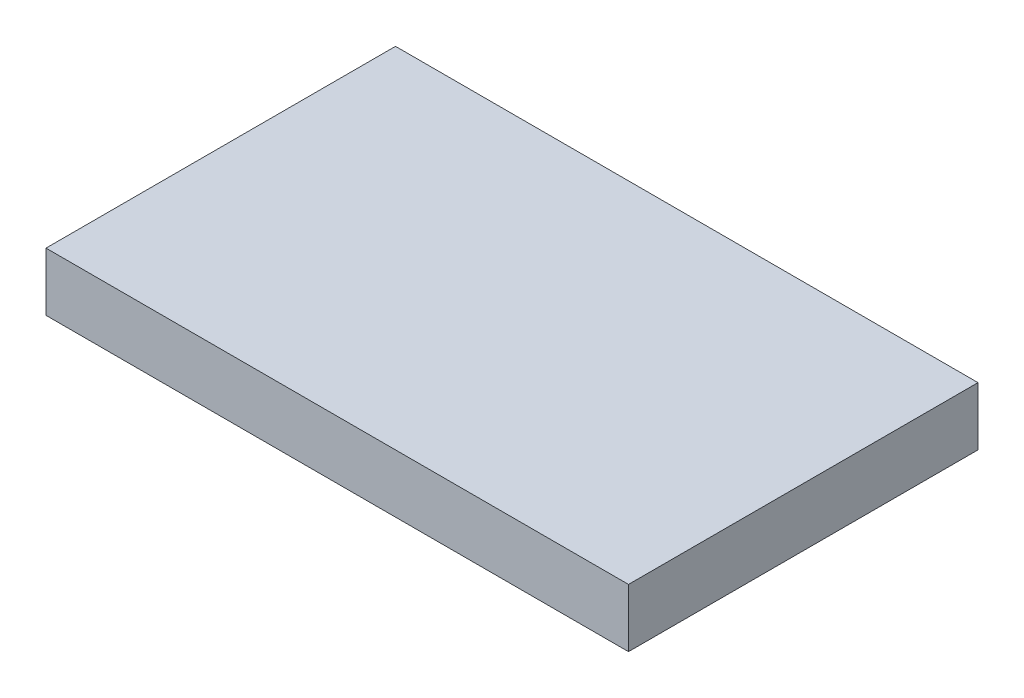
from build123d import *

# Parameters (mm, degrees)
SKETCH1_W           = 47.625
SKETCH1_H           = 28.575
BOSS_EXTRUDE1_DEPTH = 4.7625


with BuildPart() as part:
    # Sketch1 → Boss-Extrude1 (new body)
    with BuildSketch(Plane(origin=(0, 0, 0), x_dir=(1, 0, 0), z_dir=(0, 1, 0))):
        with Locations((23.8125, -14.2875)):
            Rectangle(SKETCH1_W, SKETCH1_H)
    extrude(amount=BOSS_EXTRUDE1_DEPTH)


solid = part.part
